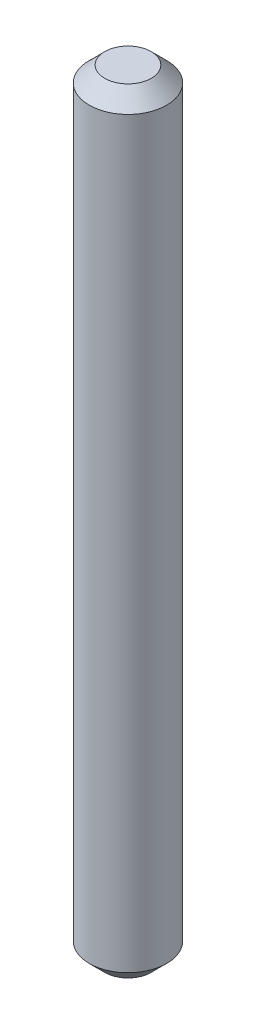
from build123d import *

# Parameters (mm, degrees)
SKETCH1_R           = 2.5
BOSS_EXTRUDE1_DEPTH = 50
CHAMFER1_SIZE       = 1


with BuildPart() as part:
    # Sketch1 → Boss-Extrude1 (new body)
    with BuildSketch(Plane(origin=(0, 0, 0), x_dir=(1, 0, 0), z_dir=(0, 1, 0))):
        Circle(SKETCH1_R)
    extrude(amount=BOSS_EXTRUDE1_DEPTH)

    # Chamfer1
    chamfer1_edges = [part.edges().sort_by_distance(p)[0] for p in [
        (-2.5, 0, 0),
        (-2.5, 50, 0),
    ]]
    chamfer(chamfer1_edges, length=CHAMFER1_SIZE)


solid = part.part
